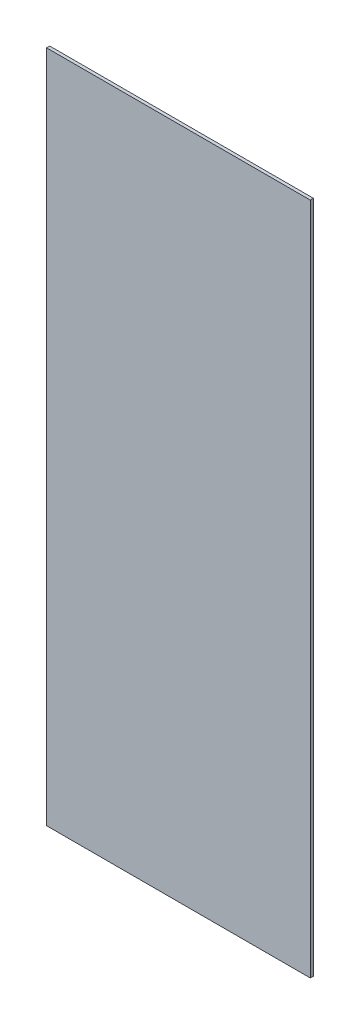
from build123d import *

# Parameters (mm, degrees)
SKICA1_W                = 252.5
SKICA1_H                = 645
P_IDAT_VYSUNUT_M1_DEPTH = 3


with BuildPart() as part:
    # Skica1 → Přidat vysunutím1 (new body)
    with BuildSketch(Plane.XY):
        Rectangle(SKICA1_W, SKICA1_H)
    extrude(amount=P_IDAT_VYSUNUT_M1_DEPTH)


solid = part.part
